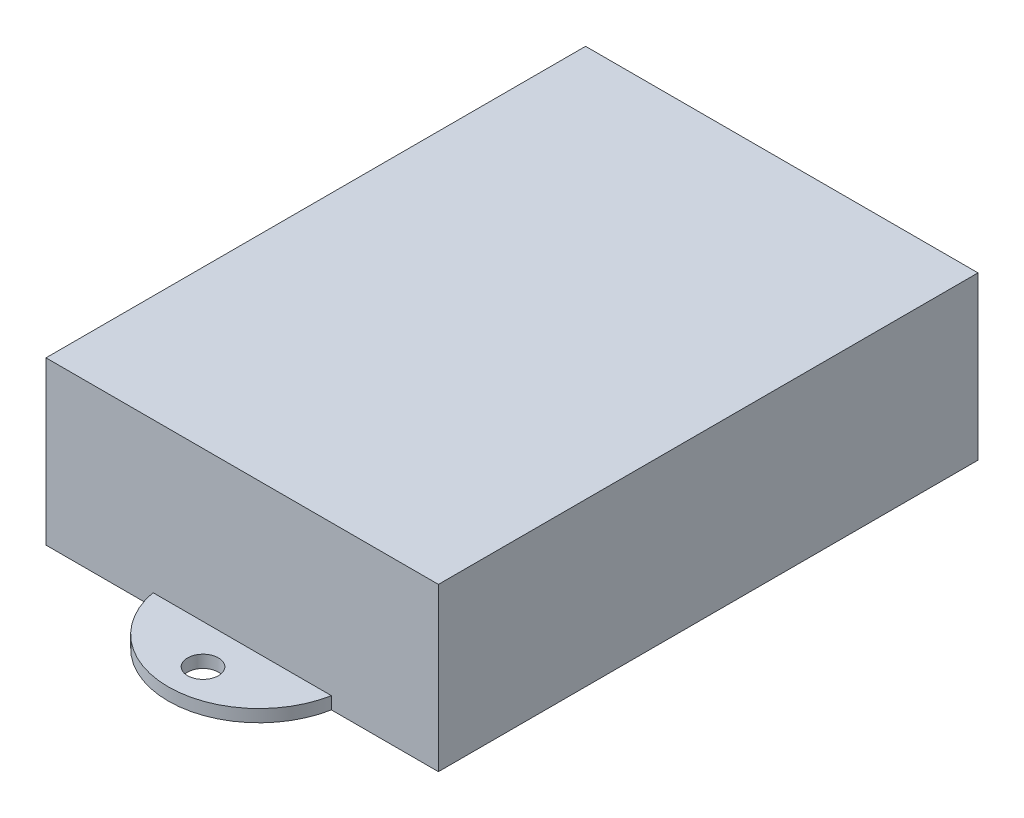
from build123d import *

# Parameters (mm, degrees)
SKETCH1_W           = 50.8
SKETCH1_H           = 69.85
BOSS_EXTRUDE1_DEPTH = 21
BOSS_EXTRUDE2_DEPTH = 1.6
SKETCH3_R           = 2
CUT_EXTRUDE1_DEPTH  = 2.6


with BuildPart() as part:
    # Sketch1 → Boss-Extrude1 (new body)
    with BuildSketch(Plane(origin=(0, 0, 0), x_dir=(1, 0, 0), z_dir=(0, 1, 0))):
        with Locations((25.4, 34.925)):
            Rectangle(SKETCH1_W, SKETCH1_H)
    extrude(amount=BOSS_EXTRUDE1_DEPTH)

    # Sketch2 → Boss-Extrude2 (add)
    with BuildSketch(Plane.XZ):
        with BuildLine():
            Line((37.15368799, -2.17868799), (37.15368799, -67.67131201))
            ThreePointArc((37.15368799, -67.67131201), (25.4, -79.425), (13.64631201, -67.67131201))
            Line((13.64631201, -67.67131201), (13.64631201, -2.17868799))
            ThreePointArc((13.64631201, -2.17868799), (25.4, 9.575), (37.15368799, -2.17868799))
        make_face()
    extrude(amount=-BOSS_EXTRUDE2_DEPTH)

    # Sketch3 → Cut-Extrude1 (cut, through all)
    with BuildSketch(Plane(origin=(0, 1.6, 0), x_dir=(1, 0, 0), z_dir=(0, 1, 0))):
        with Locations((25.4, 74.925)):
            Circle(SKETCH3_R)
        with Locations((25.4, -5.075)):
            Circle(SKETCH3_R)
    extrude(amount=-CUT_EXTRUDE1_DEPTH, mode=Mode.SUBTRACT)


solid = part.part
